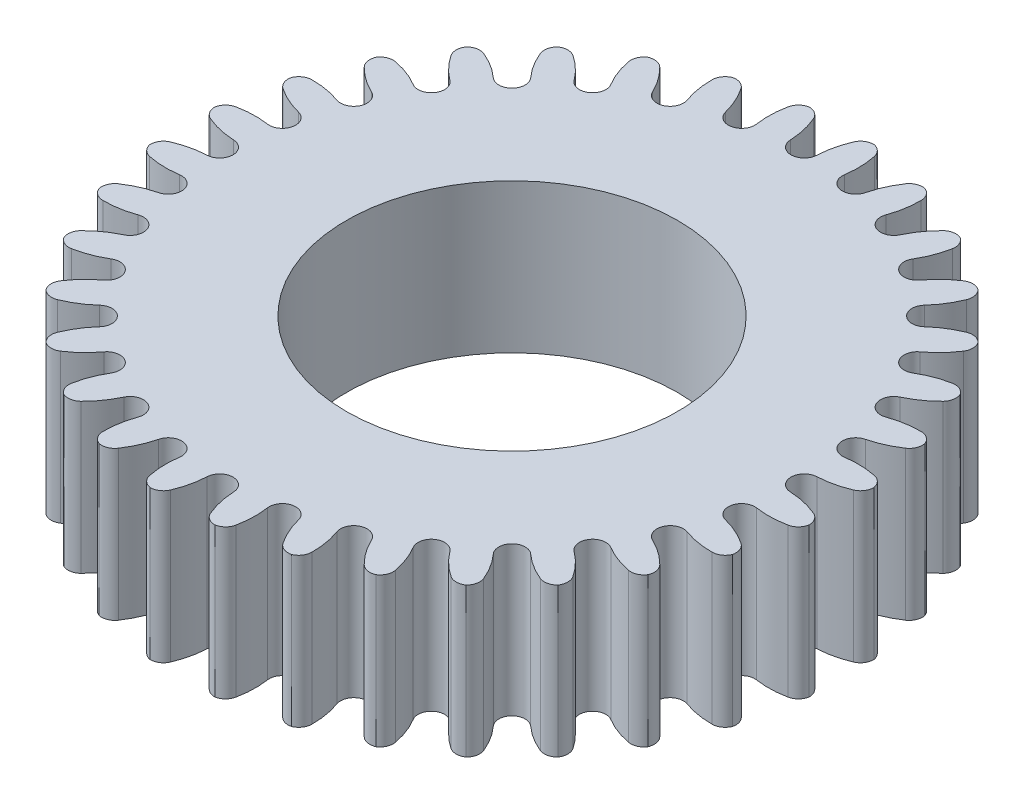
from build123d import *

# Parameters (mm, degrees)
SKETCH1_R           = 20
BOSS_EXTRUDE1_DEPTH = 9
CUT_EXTRUDE1_DEPTH  = 9
CIRPATTERN1_COUNT   = 32
SKETCH4_R           = 10
CUT_EXTRUDE3_DEPTH  = 9


with BuildPart() as part:
    # Sketch1 → Boss-Extrude1 (new body)
    with BuildSketch(Plane(origin=(0, 0, 0), x_dir=(1, 0, 0), z_dir=(0, 1, 0))):
        Circle(SKETCH1_R)
    extrude(amount=BOSS_EXTRUDE1_DEPTH)

    # Sketch3 → Cut-Extrude1 (cut)
    with BuildSketch(Plane.XZ):
        with BuildLine():
            ThreePointArc((1.210058579, -19.414796769), (0.924049006, -18.533003155), (0.799158179, -17.614437026))
            ThreePointArc((0.799158179, -17.614437026), (0, -16.851127686), (-0.799158179, -17.614437026))
            ThreePointArc((-0.799158179, -17.614437026), (-0.924049006, -18.533003155), (-1.210058579, -19.414796769))
            ThreePointArc((-1.210058579, -19.414796769), (-1.539378457, -19.790081861), (-2.027084597, -19.897008017))
            ThreePointArc((-2.027084597, -19.897008017), (0, -20), (2.027084597, -19.897008017))
            ThreePointArc((2.027084597, -19.897008017), (1.539378457, -19.790081861), (1.210058579, -19.414796769))
        make_face()
    cut_extrude1 = extrude(amount=-CUT_EXTRUDE1_DEPTH, mode=Mode.SUBTRACT)

    # CirPattern1: Cut-Extrude1 ×32 about axis
    cirpattern1_axis = Axis((0, 0, 0), (0, 1, 0))
    for i in range(1, CIRPATTERN1_COUNT):
        add(cut_extrude1.rotate(cirpattern1_axis, i * 360 / CIRPATTERN1_COUNT), mode=Mode.SUBTRACT)

    # Sketch4 → Cut-Extrude3 (cut)
    with BuildSketch(Plane.XZ):
        Circle(SKETCH4_R)
    extrude(amount=-CUT_EXTRUDE3_DEPTH, mode=Mode.SUBTRACT)


solid = part.part
